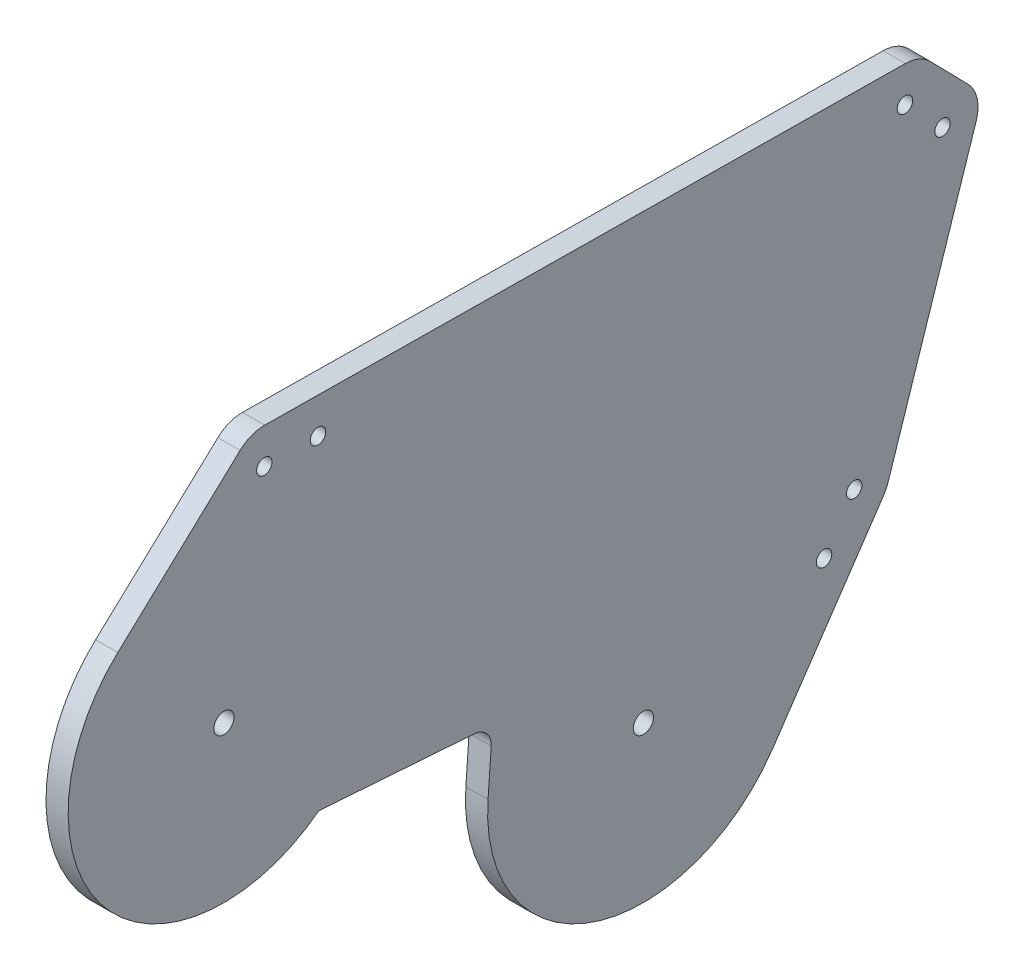
from build123d import *

# Parameters (mm, degrees)
SKETCH1_R           = 1.7272
SKETCH1_R_2         = 2.25425
BOSS_EXTRUDE1_DEPTH = 4.953


with BuildPart() as part:
    # Sketch1 → Boss-Extrude1 (new body)
    with BuildSketch(Plane(origin=(0, 0, 0), x_dir=(0, 0, -1), z_dir=(1, 0, 0))):
        with BuildLine():
            Line((-353.601711985, 25.477997798), (-361.991932565, 34.057286733))
            ThreePointArc((-361.991932565, 34.057286733), (-364.547713568, 35.80650286), (-367.578343358, 36.444512791))
            Line((-367.578343358, 36.444512791), (-510.682190934, 38.038925927))
            ThreePointArc((-510.682190934, 38.038925927), (-513.636251412, 37.504085531), (-516.180391889, 35.910386439))
            Line((-516.180391889, 35.910386439), (-543.504008498, 10.46228671))
            ThreePointArc((-543.504008498, 10.46228671), (-546.343088738, -37.498931011), (-498.569252083, -42.597883175))
            Line((-498.569252083, -42.597883175), (-463.788130796, -45.097087093))
            ThreePointArc((-463.788130796, -45.097087093), (-461.050944436, -46.468361622), (-460.085098917, -49.373482176))
            Line((-460.085098917, -49.373482176), (-460.801802922, -59.347765878))
            ThreePointArc((-460.801802922, -59.347765878), (-437.483960059, -94.727435258), (-397.273694981, -81.364150349))
            Line((-397.273694981, -81.364150349), (-372.43498101, -44.703357168))
            ThreePointArc((-372.43498101, -44.703357168), (-371.88030639, -43.747530325), (-371.463761272, -42.723929302))
            Line((-371.463761272, -42.723929302), (-351.734061333, 17.455422825))
            ThreePointArc((-351.734061333, 17.455422825), (-351.545777131, 21.727936738), (-353.601711985, 25.477997798))
        make_face()
        with Locations((-359.276554144, 19.928216477)):
            Circle(SKETCH1_R, mode=Mode.SUBTRACT)
        with Locations((-367.666774725, 28.507505411)):
            Circle(SKETCH1_R, mode=Mode.SUBTRACT)
        with Locations((-510.7706223, 30.101918548)):
            Circle(SKETCH1_R, mode=Mode.SUBTRACT)
        with Locations((-379.006254083, -40.251135649)):
            Circle(SKETCH1_R, mode=Mode.SUBTRACT)
        with Locations((-426.087206182, -61.842189663)):
            Circle(SKETCH1_R_2, mode=Mode.SUBTRACT)
        with Locations((-519.783421193, -15.006500358)):
            Circle(SKETCH1_R_2, mode=Mode.SUBTRACT)
        with Locations((-385.737171654, -50.185658721)):
            Circle(SKETCH1_R, mode=Mode.SUBTRACT)
        with Locations((-498.771367049, 29.968227033)):
            Circle(SKETCH1_R, mode=Mode.SUBTRACT)
    extrude(amount=-BOSS_EXTRUDE1_DEPTH)


solid = part.part
